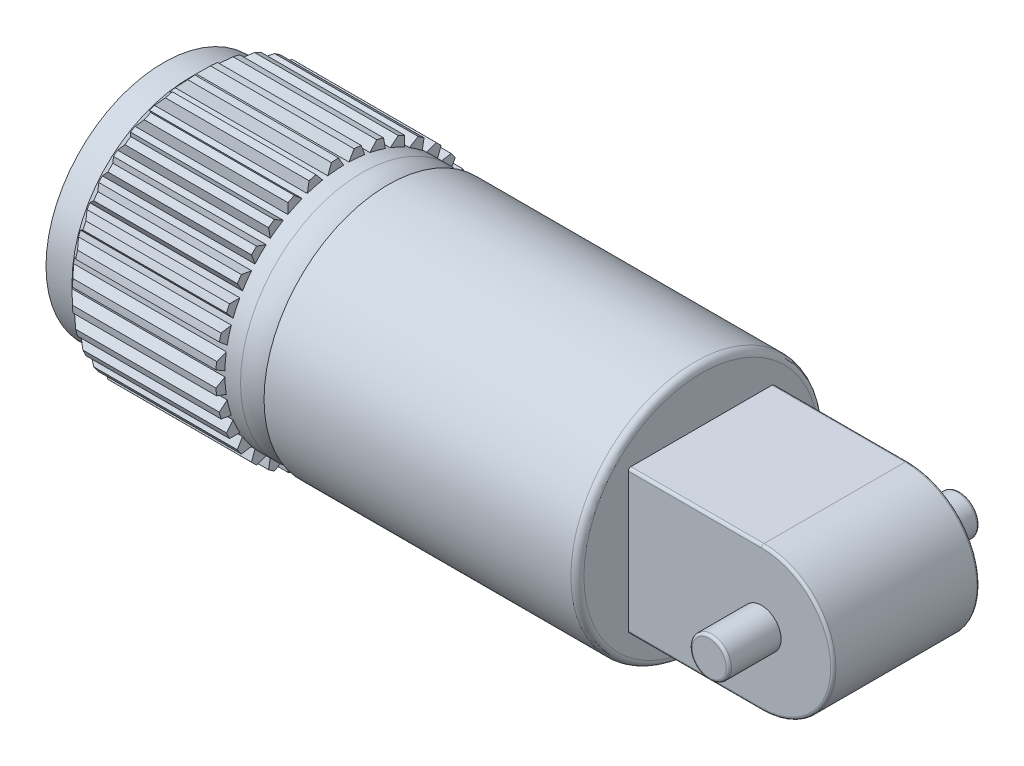
from build123d import *

# Parameters (mm, degrees)
FILLET_1_R               = 0.25
EXTRUDE_1_DEPTH          = 2.8
FILLET_2_R               = 0.1
SKETCH_3_R               = 0.75
EXTRUDE_2_DEPTH          = 2
FILLET_3_R               = 0.1
FILLET_3_OF_MIRROR_1_R   = 0.1
CUT_EXTRUDE_1_DEPTH      = 8
PATTERN_CIRCULAR_1_COUNT = 36


with BuildPart() as part:
    # Эскиз1 → Повернуть1 (revolve)
    with BuildSketch(Plane.XY):
        with BuildLine():
            Line((1, 0), (20.6, 0))
            Line((20.6, 0), (20.6, 4.75))
            Line((20.6, 4.75), (8.6, 4.75))
            Line((8.6, 4.75), (8.6, 4.2989996))
            ThreePointArc((8.6, 4.2989996), (8.129905954, 4.559701851), (7.6, 4.65))
            Line((7.6, 4.65), (7, 4.65))
            Line((7, 4.65), (7, 5))
            Line((7, 5), (1.5, 5))
            Line((1.5, 5), (1, 4.5))
            Line((1, 4.5), (0, 4.5))
            Line((0, 4.5), (0, 3.3))
            Line((0, 3.3), (1, 3.3))
            Line((1, 3.3), (1, 2.62))
            Line((1, 2.62), (5, 2.62))
            Line((5, 2.62), (5, 2.35))
            Line((5, 2.35), (3, 2.35))
            Line((3, 2.35), (3, 2.25))
            Line((3, 2.25), (3.05, 2.25))
            Line((3.05, 2.25), (3.05, 0.45))
            Line((3.05, 0.45), (1.45, 0.45))
            ThreePointArc((1.45, 0.45), (1.131801948, 0.318198052), (1, 0))
        make_face()
    revolve(axis=Axis((1, 0, 0), (1, 0, 0)))

    # Скругление1
    fillet_1_edges = [part.edges().sort_by_distance(p)[0] for p in [
        (20.6, -4.75, 0),
    ]]
    fillet(fillet_1_edges, radius=FILLET_1_R)

    # Эскиз2 → Бобышка-Вытянуть1 (add, symmetric)
    with BuildSketch(Plane.XY):
        with BuildLine():
            Line((20.6, -2.75), (25.7, -2.75))
            ThreePointArc((25.7, -2.75), (28.45, 0), (25.7, 2.75))
            Line((25.7, 2.75), (20.6, 2.75))
            Line((20.6, 2.75), (20.6, -2.75))
        make_face()
    extrude(amount=EXTRUDE_1_DEPTH, both=True)

    # Скругление2
    fillet_2_edges = [part.edges().sort_by_distance(p)[0] for p in [
        (23.15, -2.75, -2.8),
        (28.45, 0, -2.8),
        (23.15, 2.75, -2.8),
        (23.15, -2.75, 2.8),
        (28.45, 0, 2.8),
        (23.15, 2.75, 2.8),
    ]]
    fillet(fillet_2_edges, radius=FILLET_2_R)

    # Эскиз3 → Бобышка-Вытянуть2 (add)
    with BuildSketch(Plane.XY.offset(2.8)):
        with Locations((25.7, 0)):
            Circle(SKETCH_3_R)
    extrude_2 = extrude(amount=EXTRUDE_2_DEPTH)

    # Скругление3
    fillet_3_edges = [part.edges().sort_by_distance(p)[0] for p in [
        (24.95, 0, 4.8),
    ]]
    fillet(fillet_3_edges, radius=FILLET_3_R)

    # Зеркальное отражение1: Бобышка-Вытянуть2 across plane
    add(extrude_2.mirror(Plane.XY))

    # Скругление3 of Зеркальное отражение1
    fillet_3_of_mirror_1_edges = [part.edges().sort_by_distance(p)[0] for p in [
        (24.95, 0, -4.8),
    ]]
    fillet(fillet_3_of_mirror_1_edges, radius=FILLET_3_OF_MIRROR_1_R)

    # Эскиз4 → Вырез-Вытянуть1 (cut, through all)
    with BuildSketch(Plane(origin=(7, 0, 0), x_dir=(0, 0, -1), z_dir=(1, 0, 0))):
        with BuildLine():
            Line((-0.3, 4.990991885), (-0.102476231, 4.648870682))
            ThreePointArc((-0.102476231, 4.648870682), (0, 4.65), (0.102476231, 4.648870682))
            Line((0.102476231, 4.648870682), (0.3, 4.990991885))
            ThreePointArc((0.3, 4.990991885), (0, 5), (-0.3, 4.990991885))
        make_face()
    cut_extrude_1 = extrude(amount=-CUT_EXTRUDE_1_DEPTH, mode=Mode.SUBTRACT)

    # Круговой массив1: Вырез-Вытянуть1 ×36 about axis
    pattern_circular_1_axis = Axis((0, 0, 0), (1, 0, 0))
    for i in range(1, PATTERN_CIRCULAR_1_COUNT):
        add(cut_extrude_1.rotate(pattern_circular_1_axis, i * 360 / PATTERN_CIRCULAR_1_COUNT), mode=Mode.SUBTRACT)


solid = part.part
